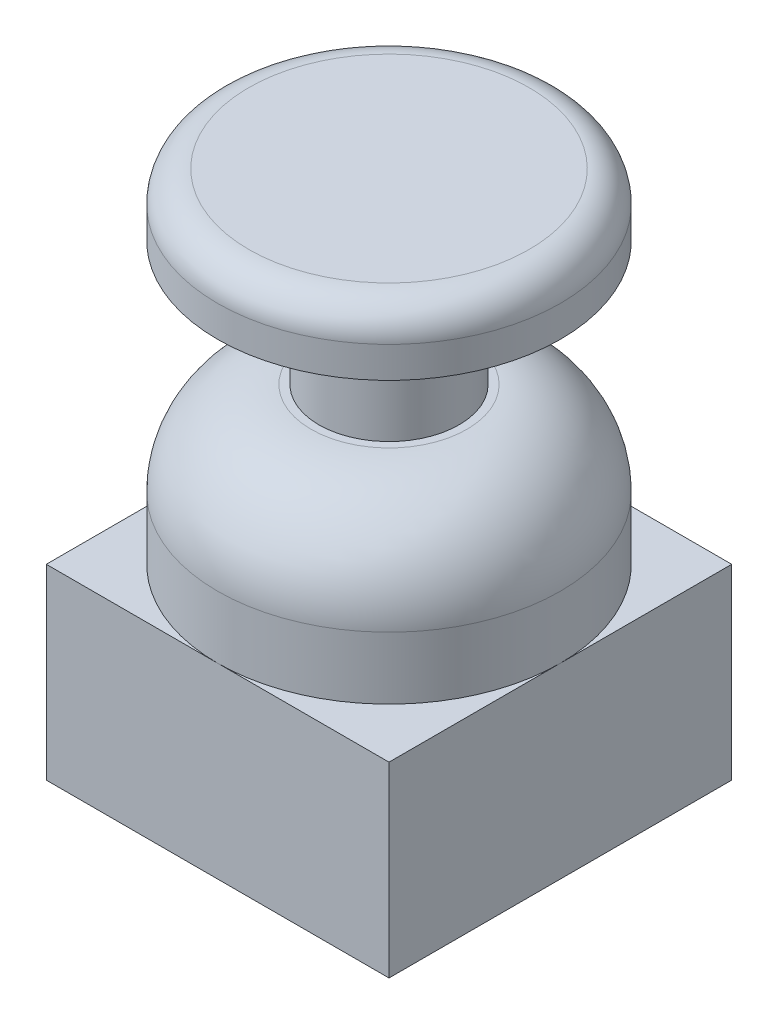
from build123d import *

# Parameters (mm, degrees)
SKETCH2_W         = 22
SKETCH2_H         = 22
SWITCH_BASE_DEPTH = 12


with BuildPart() as part:
    # Sketch1 → Stick Revolve (revolve)
    with BuildSketch(Plane.XY):
        with BuildLine():
            Line((0, 0), (-11, 0))
            Line((-11, 0), (-11, 16))
            ThreePointArc((-11, 16), (-9.242640687, 20.242640687), (-5, 22))
            Line((-5, 22), (-4.5, 22))
            Line((-4.5, 22), (-4.5, 30))
            Line((-4.5, 30), (-11, 30))
            Line((-11, 30), (-11, 32))
            ThreePointArc((-11, 32), (-10.414213562, 33.414213562), (-9, 34))
            Line((-9, 34), (0, 34))
            Line((0, 34), (0, 0))
        make_face()
    revolve(axis=Axis((0, 34, 0), (0, -1, 0)))

    # Sketch2 → Switch Base (add)
    with BuildSketch(Plane.XZ):
        Rectangle(SKETCH2_W, SKETCH2_H)
    extrude(amount=-SWITCH_BASE_DEPTH)


solid = part.part
